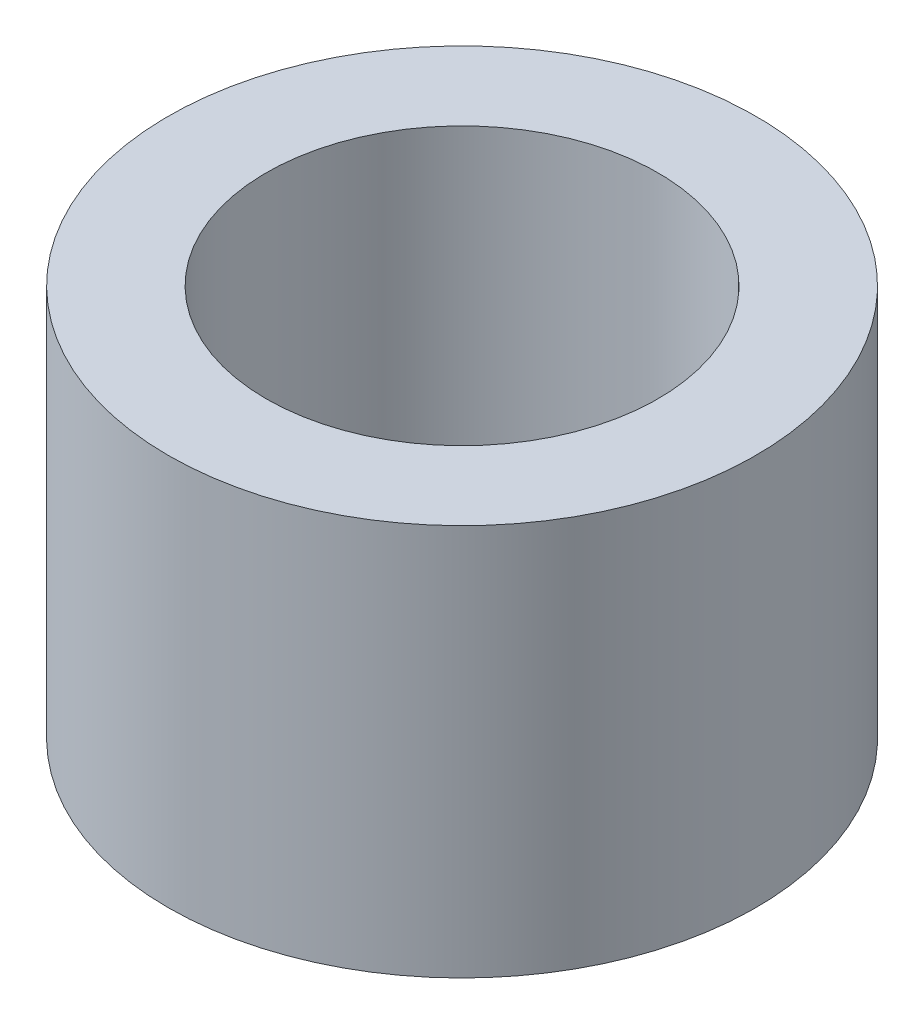
from build123d import *

# Parameters (mm, degrees)
SKETCH1_R           = 4.7625
SKETCH1_R_2         = 3.175
BOSS_EXTRUDE1_DEPTH = 6.35


with BuildPart() as part:
    # Sketch1 → Boss-Extrude1 (new body)
    with BuildSketch(Plane(origin=(0, 0, 0), x_dir=(1, 0, 0), z_dir=(0, 1, 0))):
        Circle(SKETCH1_R)
        Circle(SKETCH1_R_2, mode=Mode.SUBTRACT)
    extrude(amount=BOSS_EXTRUDE1_DEPTH)


solid = part.part
